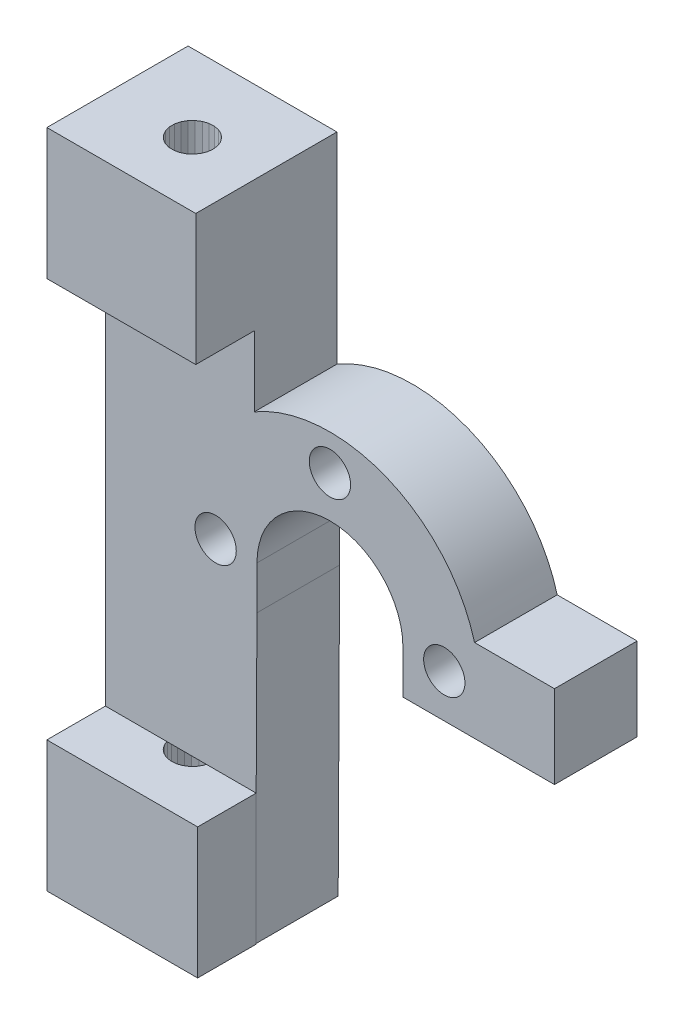
from build123d import *

# Parameters (mm, degrees)
SKETCH1_R           = 1.5
BOSS_EXTRUDE1_DEPTH = 6
SKETCH2_W           = 10.807687298
SKETCH2_H           = 9.5
SKETCH2_W_2         = 10.943994224
BOSS_EXTRUDE2_DEPTH = 4.25
CUT_EXTRUDE1_DEPTH  = 9.5
CUT_EXTRUDE2_DEPTH  = 9.5


with BuildPart() as part:
    # Sketch1 → Boss-Extrude1 (new body)
    with BuildSketch(Plane.XY.offset(84.451608182)):
        with BuildLine():
            Line((40.02344809, 11.701998712), (40.02344809, 8.566491131))
            Line((40.02344809, 8.566491131), (47.02344809, 8.566491131))
            Line((47.02344809, 8.566491131), (51.02344809, 8.566491131))
            Line((51.02344809, 8.566491131), (51.02344809, 14.59568261))
            Line((51.02344809, 14.59568261), (45.222644144, 14.59568261))
            ThreePointArc((45.222644144, 14.59568261), (38.830062222, 21.788734788), (29.231135388, 21.10630759))
            Line((29.231135388, 21.10630759), (29.231135388, 35.703275576))
            Line((29.231135388, 35.703275576), (18.42344809, 35.703275576))
            Line((18.42344809, 35.703275576), (18.42344809, 14.59568261))
            Line((18.42344809, 14.59568261), (18.42344809, 8.566491131))
            Line((18.42344809, 8.566491131), (18.42344809, -12.296724841))
            Line((18.42344809, -12.296724841), (29.320619754, -12.296724841))
            Line((29.320619754, -12.296724841), (29.42344809, 8.566491131))
            Line((29.42344809, 8.566491131), (29.42344809, 11.701998712))
            ThreePointArc((29.42344809, 11.701998712), (34.72344809, 17.001998712), (40.02344809, 11.701998712))
        make_face()
        with Locations((43.02344809, 11.701998712)):
            Circle(SKETCH1_R, mode=Mode.SUBTRACT)
        with Locations((26.42344809, 11.701998712)):
            Circle(SKETCH1_R, mode=Mode.SUBTRACT)
        with Locations((34.72344809, 20.001998712)):
            Circle(SKETCH1_R, mode=Mode.SUBTRACT)
    extrude(amount=BOSS_EXTRUDE1_DEPTH)

    # Sketch2 → Boss-Extrude2 (add)
    with BuildSketch(Plane.XY.offset(90.451608182)):
        with Locations((23.827291739, 30.953275576)):
            Rectangle(SKETCH2_W, SKETCH2_H)
        with Locations((23.895445202, -7.546724841)):
            Rectangle(SKETCH2_W_2, SKETCH2_H)
    extrude(amount=BOSS_EXTRUDE2_DEPTH)

    # Sketch3 → Cut-Extrude1 (cut)
    with BuildSketch(Plane(origin=(0, 35.703275576, 0), x_dir=(1, 0, 0), z_dir=(0, 1, 0))):
        Polygon((24.039543919, -91.507423883), (24.414807311, -91.53103291), (24.784140042, -91.460577426), (25.124363355, -91.300484473), (25.414071731, -91.060813265), (25.635078303, -90.756623289), (25.773495189, -90.407027611), (25.820620111, -90.033992408), (25.773495189, -89.660958601), (25.635078303, -89.311362458), (25.414071731, -89.007172948), (25.124363355, -88.767500808), (24.784140042, -88.607407389), (24.414807311, -88.536952836), (24.039543919, -88.560561864), (23.681945852, -88.676751805), (23.364484064, -88.878222024), (23.107096306, -89.152314914), (22.925957791, -89.481805665), (22.832445554, -89.845992839), (22.832445554, -90.221992442), (22.925957791, -90.586179616), (23.107096306, -90.915670833), (23.364484064, -91.189762792), (23.681945852, -91.391233476), align=None)
    extrude(amount=-CUT_EXTRUDE1_DEPTH, mode=Mode.SUBTRACT)

    # Sketch4 → Cut-Extrude2 (cut)
    with BuildSketch(Plane.XZ.offset(12.296724841)):
        Polygon((25.27675753, 88.878222024), (24.959288291, 88.676751805), (24.601690225, 88.560561864), (24.226434282, 88.536952836), (23.857094101, 88.607407389), (23.516878239, 88.767500808), (23.227169863, 89.007172948), (23.00615584, 89.311362458), (22.867746405, 89.660958601), (22.820621482, 90.033992408), (22.867746405, 90.407027611), (23.00615584, 90.756623289), (23.227169863, 91.060813265), (23.516878239, 91.300484473), (23.857094101, 91.460577426), (24.226434282, 91.53103291), (24.601690225, 91.507423883), (24.959288291, 91.391233476), (25.27675753, 91.189762792), (25.534145287, 90.915670833), (25.715283803, 90.586179616), (25.80879604, 90.221992442), (25.80879604, 89.845992839), (25.715283803, 89.481805665), (25.534145287, 89.152314914), align=None)
    extrude(amount=-CUT_EXTRUDE2_DEPTH, mode=Mode.SUBTRACT)


solid = part.part
